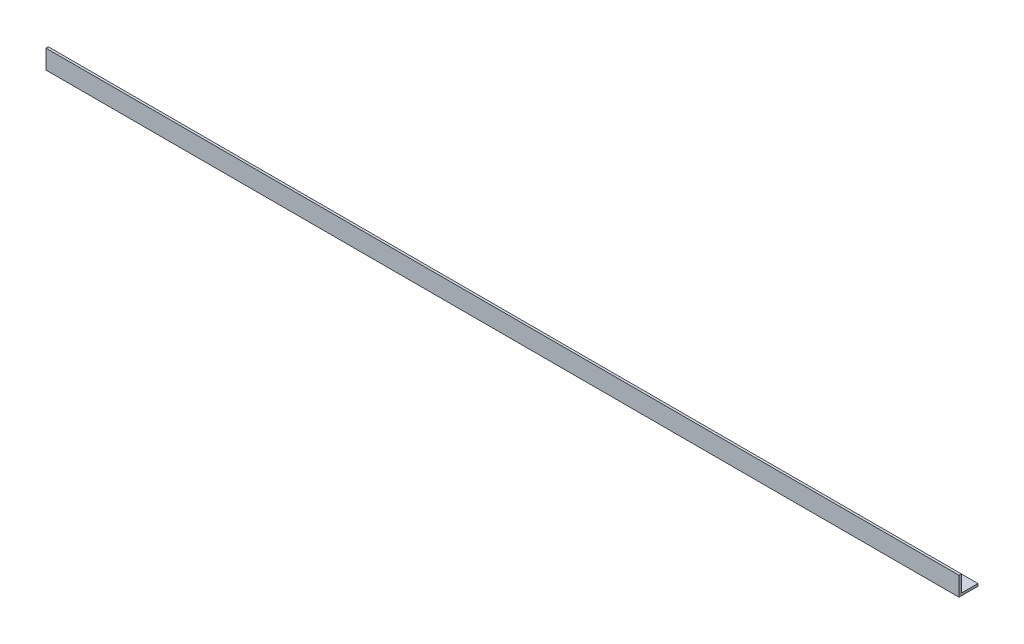
from build123d import *

# Parameters (mm, degrees)
BOSS_EXTRUDE1_DEPTH = 609.6


with BuildPart() as part:
    # Sketch1 → Boss-Extrude1 (new body, symmetric)
    with BuildSketch(Plane(origin=(0, 0, 0), x_dir=(0, 0, -1), z_dir=(1, 0, 0))):
        Polygon((0, 0), (0, 25.4), (3.175, 25.4), (3.175, 3.175), (25.4, 3.175), (25.4, 0), align=None)
    extrude(amount=BOSS_EXTRUDE1_DEPTH, both=True)


solid = part.part
